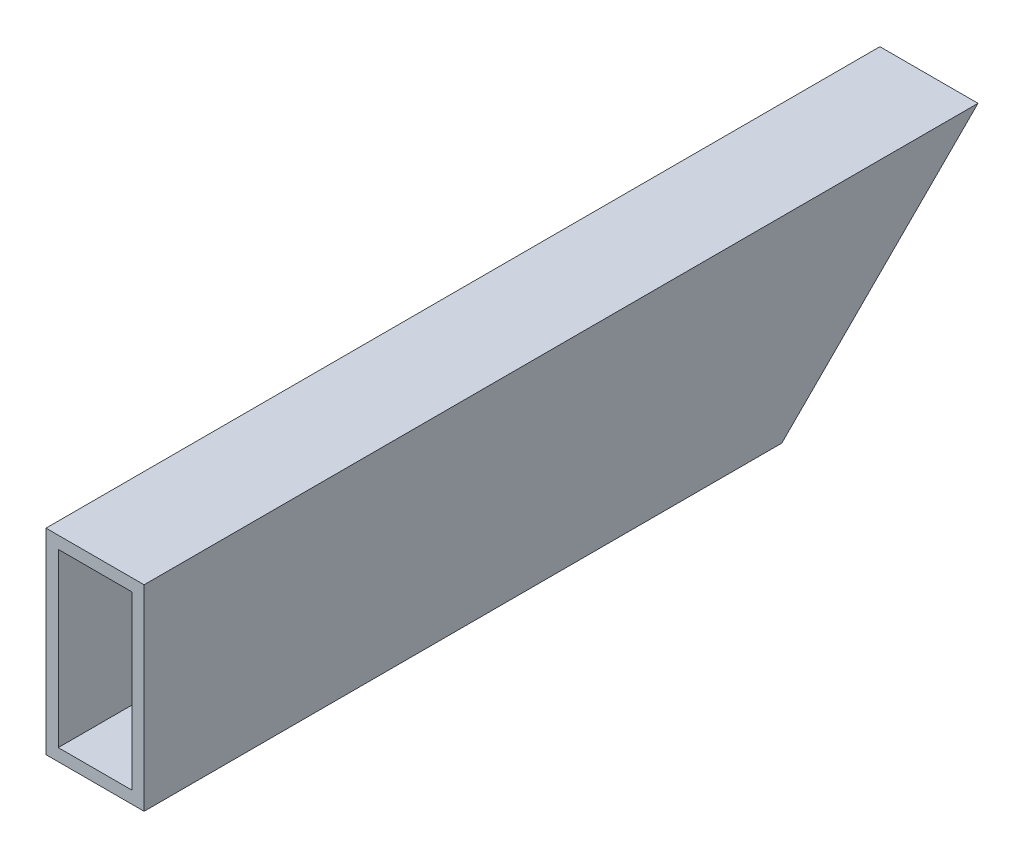
from build123d import *

# Parameters (mm, degrees)
SKETCH1_W           = 25.4
SKETCH1_H           = 50.8
SKETCH1_W_2         = 19.05
SKETCH1_H_2         = 44.45
BOSS_EXTRUDE1_DEPTH = 215.9
CUT_EXTRUDE1_DEPTH  = 25.4


with BuildPart() as part:
    # Sketch1 → Boss-Extrude1 (new body)
    with BuildSketch(Plane.XY):
        with Locations((-12.7, 25.4)):
            Rectangle(SKETCH1_W, SKETCH1_H)
        with Locations((-12.7, 25.4)):
            Rectangle(SKETCH1_W_2, SKETCH1_H_2, mode=Mode.SUBTRACT)
    extrude(amount=BOSS_EXTRUDE1_DEPTH)

    # Sketch2 → Cut-Extrude1 (cut)
    with BuildSketch(Plane(origin=(0, 0, 0), x_dir=(0, 0, -1), z_dir=(1, 0, 0))):
        Polygon((0, 50.8), (-50.8, 0), (0, 0), align=None)
    extrude(amount=-CUT_EXTRUDE1_DEPTH, mode=Mode.SUBTRACT)


solid = part.part
